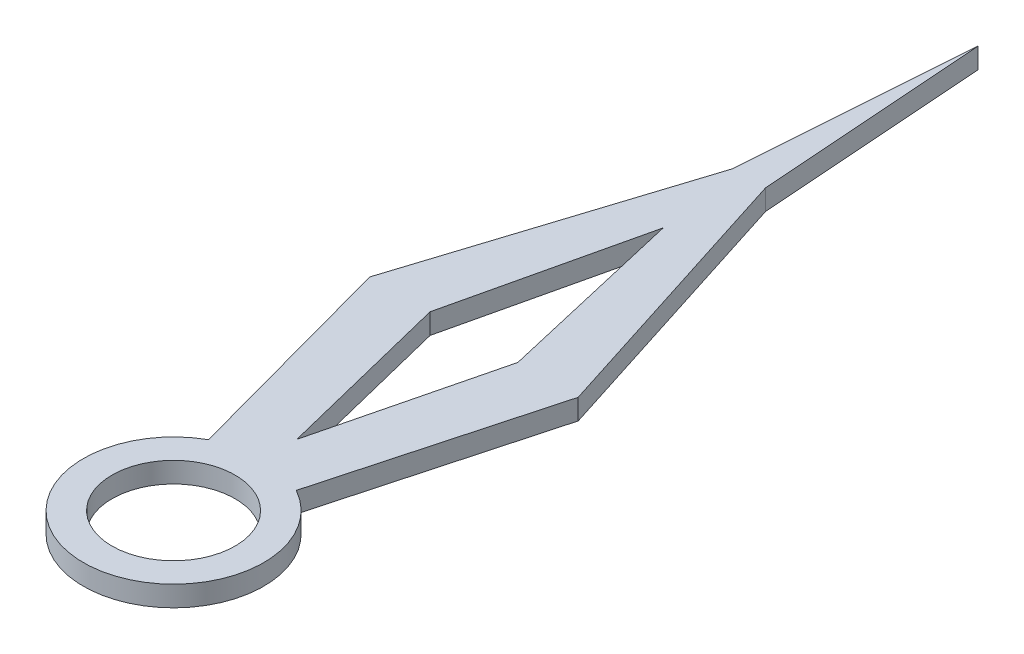
from build123d import *

# Parameters (mm, degrees)
SKETCH1_R           = 30
BOSS_EXTRUDE1_DEPTH = 10


with BuildPart() as part:
    # Sketch1 → Boss-Extrude1 (new body)
    with BuildSketch(Plane(origin=(0, 0, 0), x_dir=(1, 0, 0), z_dir=(0, 1, 0))):
        with BuildLine():
            Line((-21.391856852, 38.422206609), (-50.810091155, 146.458168919))
            Line((-50.810091155, 146.458168919), (-8.048011127, 280.566292355))
            Line((-8.048011127, 280.566292355), (0, 392.18316322))
            Line((0, 392.18316322), (8.048011127, 280.566292355))
            Line((8.048011127, 280.566292355), (50.810091155, 146.458168919))
            Line((50.810091155, 146.458168919), (21.391856852, 38.422206609))
            ThreePointArc((21.391856852, 38.422206609), (0, -43.97587407), (-21.391856852, 38.422206609))
        make_face()
        Circle(SKETCH1_R, mode=Mode.SUBTRACT)
        Polygon((0, 238.738180914), (-21.391856852, 146.458168919), (0, 60.077729237), (21.391856852, 146.458168919), align=None, mode=Mode.SUBTRACT)
    extrude(amount=BOSS_EXTRUDE1_DEPTH)


solid = part.part
